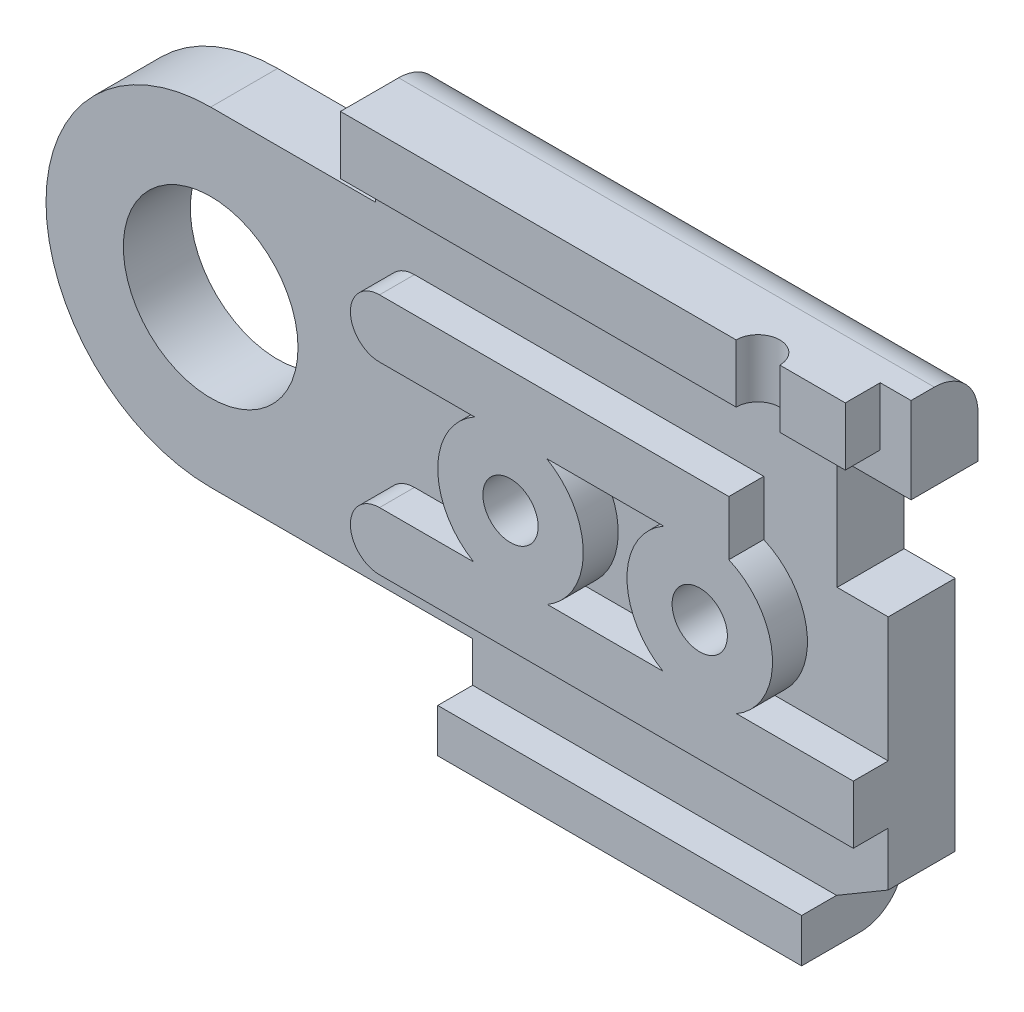
from build123d import *

# Parameters (mm, degrees)
BOSS_EXTRUDE1_DEPTH  = 2
BOSS_EXTRUDE6_DEPTH  = 4.5
CUT_EXTRUDE6_DEPTH   = 4.5
BOSS_EXTRUDE14_DEPTH = 2.3
SKETCH32_R           = 3
CUT_EXTRUDE7_DEPTH   = 2.3
SKETCH33_W           = 17.343145750507624
SKETCH33_H           = 2
BOSS_EXTRUDE15_DEPTH = 1.2
CUT_EXTRUDE8_DEPTH   = 2.4
CUT_EXTRUDE9_DEPTH   = 4.3999999999999995
SKETCH37_R           = 3.899999999999994
BOSS_EXTRUDE16_DEPTH = 4.4
CUT_EXTRUDE10_DEPTH  = 39.60291748102272
SKETCH43_R           = 2.5000000000000004
SKETCH43_R_2         = 2.4999999999999982
BOSS_EXTRUDE17_DEPTH = 1.2
SKETCH44_R           = 0.9499999999999992
SKETCH44_R_2         = 0.9500000000000008
CUT_EXTRUDE11_DEPTH  = 40.360198653546576
SKETCH45_R           = 1.9999999999999996
SKETCH45_R_2         = 2.000000000000003
CUT_EXTRUDE12_DEPTH  = 4.5
SKETCH49_R           = 0.7500000000000021
CUT_EXTRUDE13_DEPTH  = 3
CUT_EXTRUDE14_DEPTH  = 6.8
FILLET1_R            = 1.5
FILLET3_R            = 1


with BuildPart() as part:
    # Sketch3 → Boss-Extrude1 (new body)
    with BuildSketch(Plane.XY):
        with BuildLine():
            Line((8.000000000000002, 0), (8.999999999999993, -2.5431457505076343))
            Line((8.999999999999993, -2.5431457505076343), (8.999999999999993, -7.04314575050762))
            Line((8.999999999999993, -7.04314575050762), (21.50000000000003, -7.043145750507617))
            Line((21.50000000000003, -7.043145750507617), (25.05025253169419, -4.949747468305846))
            ThreePointArc((25.05025253169419, -4.949747468305846), (36.46715672757901, -2.678784026555599), (30, 7.000000000000014))
            Line((30, 7.000000000000014), (26.999999999999996, 7.456854249492377))
            Line((26.999999999999996, 7.456854249492377), (5.656854249492369, 7.456854249492377))
            Line((5.656854249492369, 7.456854249492377), (5.656854249492376, 5.656854249492382))
            ThreePointArc((5.656854249492376, 5.656854249492382), (7.391036260090296, 3.061467458920721), (8.000000000000002, 0))
        make_face()
    extrude(amount=BOSS_EXTRUDE1_DEPTH)

    # Sketch22 → Boss-Extrude6 (add)
    with BuildSketch(Plane.XY.offset(2)):
        with BuildLine():
            Line((5.656854249492376, 7.456854249492377), (21.50000000000004, 7.456854249492377))
            Line((21.50000000000004, 7.456854249492377), (26.999999999999996, 7.456854249492377))
            Line((26.999999999999996, 7.456854249492377), (26.999999999999996, 2.1288604946885763))
            Line((26.999999999999996, 2.1288604946885763), (23.27512626584711, 2.128860494688576))
            Line((23.27512626584711, 2.128860494688576), (23.27512626584711, -5.996446609406731))
            Line((23.27512626584711, -5.996446609406731), (21.50000000000003, -7.043145750507617))
            Line((21.50000000000003, -7.043145750507617), (8.999999999999993, -7.04314575050762))
            Line((8.999999999999993, -7.04314575050762), (8.999999999999993, -2.5431457505076343))
            Line((8.999999999999993, -2.5431457505076343), (7.999999999999998, 0))
            ThreePointArc((7.999999999999998, 0), (7.391036260090291, 3.061467458920719), (5.656854249492376, 5.656854249492382))
            Line((5.656854249492376, 5.656854249492382), (5.656854249492376, 7.456854249492377))
        make_face()
    extrude(amount=BOSS_EXTRUDE6_DEPTH)

    # Sketch26 → Cut-Extrude6 (cut)
    with BuildSketch(Plane.XY.offset(2)):
        Polygon((18.098080447707712, 5.299999999999999), (2.5300524575164793, 5.299999999999999), (2.5300524575164793, 4), (18.098080447707712, 4), (26.999999999999996, 4), (26.999999999999996, 5.299999999999999), align=None)
    extrude(amount=CUT_EXTRUDE6_DEPTH, mode=Mode.SUBTRACT)


with BuildPart() as body_2:
    # Sketch31 → Boss-Extrude14 (new body)
    with BuildSketch(Plane.XY.offset(6.5)):
        with BuildLine():
            Line((2.4326880657739025, 5.656854249492382), (0, 5.656854249492382))
            ThreePointArc((0, 5.656854249492382), (-5.656854249492382, 6.9e-16), (0, -5.656854249492382))
            Line((0, -5.656854249492382), (9.000000000000004, -5.656854249492382))
            Line((9.000000000000004, -5.656854249492382), (8.999999999999993, -7.04314575050762))
            Line((8.999999999999993, -7.04314575050762), (8.999999999999993, -8.54314575050762))
            Line((8.999999999999993, -8.54314575050762), (21.50000000000003, -8.54314575050762))
            Line((21.50000000000003, -8.54314575050762), (21.50000000000003, -7.043145750507617))
            Line((21.50000000000003, -7.043145750507617), (23.27512626584711, -5.996446609406731))
            Line((23.27512626584711, -5.996446609406731), (23.27512626584711, 2.128860494688576))
            Line((23.27512626584711, 2.128860494688576), (26.999999999999996, 2.1288604946885763))
            Line((26.999999999999996, 2.1288604946885763), (26.999999999999996, 7.456854249492377))
            Line((26.999999999999996, 7.456854249492377), (26.999999999999996, 8.956854249492377))
            Line((26.999999999999996, 8.956854249492377), (5.656854249492376, 8.956854249492377))
            Line((5.656854249492376, 8.956854249492377), (5.656854249492376, 7.456854249492377))
            Line((5.656854249492376, 7.456854249492377), (5.656854249492376, 5.656854249492382))
            Line((5.656854249492376, 5.656854249492382), (2.4326880657739025, 5.656854249492382))
        make_face()
    extrude(amount=BOSS_EXTRUDE14_DEPTH)

    # Sketch32 → Cut-Extrude7 (cut)
    with BuildSketch(Plane.XY.offset(8.799999999999999)):
        Circle(SKETCH32_R)
    extrude(amount=-CUT_EXTRUDE7_DEPTH, mode=Mode.SUBTRACT)

    # Sketch33 → Boss-Extrude15 (add)
    with BuildSketch(Plane.XY.offset(8.799999999999999)):
        with Locations((14.328427124746185, 7.956854249492377)):
            Rectangle(SKETCH33_W, SKETCH33_H)
        Polygon((9.000000000000004, -7.043145750507619), (9.000000000000004, -8.54314575050762), (21.50000000000003, -8.54314575050762), (21.50000000000003, -7.043145750507617), align=None)
        with BuildLine():
            Line((7.000000000000003, -4.156854249492383), (23.275126265847117, -4.156854249492383))
            Line((23.275126265847117, -4.156854249492383), (23.275126265847113, -2.1568542494923815))
            Line((23.275126265847113, -2.1568542494923815), (7.000000000000003, -2.1568542494923832))
            ThreePointArc((7.000000000000003, -2.1568542494923832), (6.000000000000003, -3.1568542494923832), (7.000000000000003, -4.156854249492383))
        make_face()
        with BuildLine():
            Line((18.999999999999996, 2.172006245196199), (7.000000000000003, 2.172006245196201))
            ThreePointArc((7.000000000000003, 2.172006245196201), (6.0000000000000036, 3.1720062451962), (7.000000000000003, 4.172006245196199))
            Line((7.000000000000003, 4.172006245196199), (18.999999999999996, 4.172006245196199))
            Line((18.999999999999996, 4.172006245196199), (18.999999999999996, 2.172006245196199))
        make_face()
    extrude(amount=BOSS_EXTRUDE15_DEPTH)


with BuildPart() as cut_extrude8_tool:
    # Sketch35 → Cut-Extrude8 (new body)
    with BuildSketch(Plane.XY.offset(8.799999999999999)):
        Polygon((26.999999999999996, 2.1288604946885763), (26.999999999999996, 6.000000000000002), (21.520354003499165, 6.000000000000002), (21.520354003499165, 2.1288604946885754), align=None)
    extrude(amount=-CUT_EXTRUDE8_DEPTH)


with BuildPart() as part_1:
    add(part.part)

    # Cut-Extrude8: cut by cut_extrude8_tool
    add(cut_extrude8_tool.part, mode=Mode.SUBTRACT)

    # Sketch36 → Cut-Extrude9 (cut)
    with BuildSketch(Plane.XY.offset(6.3999999999999995)):
        Polygon((26.999999999999996, 2.1288604946885763), (26.999999999999996, 4), (23.30000000000004, 3.999999999999999), (23.30000000000003, 2.1288604946885754), align=None)
    extrude(amount=-CUT_EXTRUDE9_DEPTH, mode=Mode.SUBTRACT)

    # Sketch37 → Boss-Extrude16 (add)
    with BuildSketch(Plane.XY.offset(2)):
        with Locations((29.999999999999996, 1.388e-14)):
            Circle(SKETCH37_R)
    extrude(amount=BOSS_EXTRUDE16_DEPTH)

    # Sketch39 → Cut-Extrude10 (cut, through all)
    with BuildSketch(Plane.XY.offset(6.4)):
        with BuildLine():
            Line((28.999999999999993, 0.9797958971132569), (28.999999999999993, -0.9797958971132569))
            ThreePointArc((28.999999999999993, -0.9797958971132569), (31.4, 2.383e-14), (28.999999999999993, 0.9797958971132569))
        make_face()
    extrude(amount=-CUT_EXTRUDE10_DEPTH, mode=Mode.SUBTRACT)


with BuildPart() as body_2_1:
    add(body_2.part)

    # Cut-Extrude8: cut by cut_extrude8_tool
    add(cut_extrude8_tool.part, mode=Mode.SUBTRACT)

    # Sketch43 → Boss-Extrude17 (add)
    with BuildSketch(Plane.XY.offset(8.799999999999999)):
        with Locations((11.500000000000004, 0)):
            Circle(SKETCH43_R)
        with Locations((18.000000000000004, 0)):
            Circle(SKETCH43_R_2)
    extrude(amount=BOSS_EXTRUDE17_DEPTH)


with BuildPart() as cut_extrude11_tool:
    # Sketch44 → Cut-Extrude11 (new, through all)
    with BuildSketch(Plane.XY.offset(9.999999999999998)):
        with Locations((11.500000000000004, 0)):
            Circle(SKETCH44_R)
        with Locations((18.000000000000004, 0)):
            Circle(SKETCH44_R_2)
    extrude(amount=-CUT_EXTRUDE11_DEPTH)


with BuildPart() as part_2:
    add(part_1.part)

    # Cut-Extrude11: cut by cut_extrude11_tool
    add(cut_extrude11_tool.part, mode=Mode.SUBTRACT)

    # Sketch45 → Cut-Extrude12 (cut)
    with BuildSketch(Plane(origin=(0, 0, 0), x_dir=(-1, 0, 0), z_dir=(0, 0, -1))):
        with Locations((-11.500000000000004, 0)):
            Circle(SKETCH45_R)
        with Locations((-18.000000000000004, 0)):
            Circle(SKETCH45_R_2)
    extrude(amount=-CUT_EXTRUDE12_DEPTH, mode=Mode.SUBTRACT)


with BuildPart() as body_2_2:
    add(body_2_1.part)

    # Cut-Extrude11: cut by cut_extrude11_tool
    add(cut_extrude11_tool.part, mode=Mode.SUBTRACT)

    # Sketch49 → Cut-Extrude13 (cut)
    with BuildSketch(Plane.XZ.offset(-6.956854249492377)):
        with Locations((19.999999999999996, 9.999999999999998)):
            Circle(SKETCH49_R)
    extrude(amount=-CUT_EXTRUDE13_DEPTH, mode=Mode.SUBTRACT)


with BuildPart() as cut_extrude14_tool:
    # Sketch51 → Cut-Extrude14 (new body)
    with BuildSketch(Plane.XY.offset(8.799999999999999)):
        Polygon((27, 8.956854249492377), (24.058650564533934, 8.956854249492377), (24.058650564533938, 4.991269007681976), (26.999999999999996, 4.991269007681976), align=None)
    extrude(amount=-CUT_EXTRUDE14_DEPTH)


with BuildPart() as part_3:
    add(part_2.part)

    # Cut-Extrude14: cut by cut_extrude14_tool
    add(cut_extrude14_tool.part, mode=Mode.SUBTRACT)

    # Fillet3
    fillet3_edges = [part_3.edges().sort_by_distance(p)[0] for p in [
        (23.27512626584711, -5.996446609406731, 4.25),
        (24.058650564533934, 7.456854249492377, 4.25),
        (8.999999999999993, -7.04314575050762, 3.25),
        (5.656854249492373, 7.456854249492377, 3.25),
        (15.25000000000001, -7.043145750507618, 0),
        (16.328427124746185, 7.456854249492377, 0),
    ]]
    fillet(fillet3_edges, radius=FILLET3_R)


with BuildPart() as body_2_3:
    add(body_2_2.part)

    # Cut-Extrude14: cut by cut_extrude14_tool
    add(cut_extrude14_tool.part, mode=Mode.SUBTRACT)

    # Fillet1
    fillet1_edges = [body_2_3.edges().sort_by_distance(p)[0] for p in [
        (14.857752407013155, 8.956854249492377, 6.5),
        (15.25000000000001, -8.54314575050762, 6.5),
    ]]
    fillet(fillet1_edges, radius=FILLET1_R)


solid = body_2_3.part
